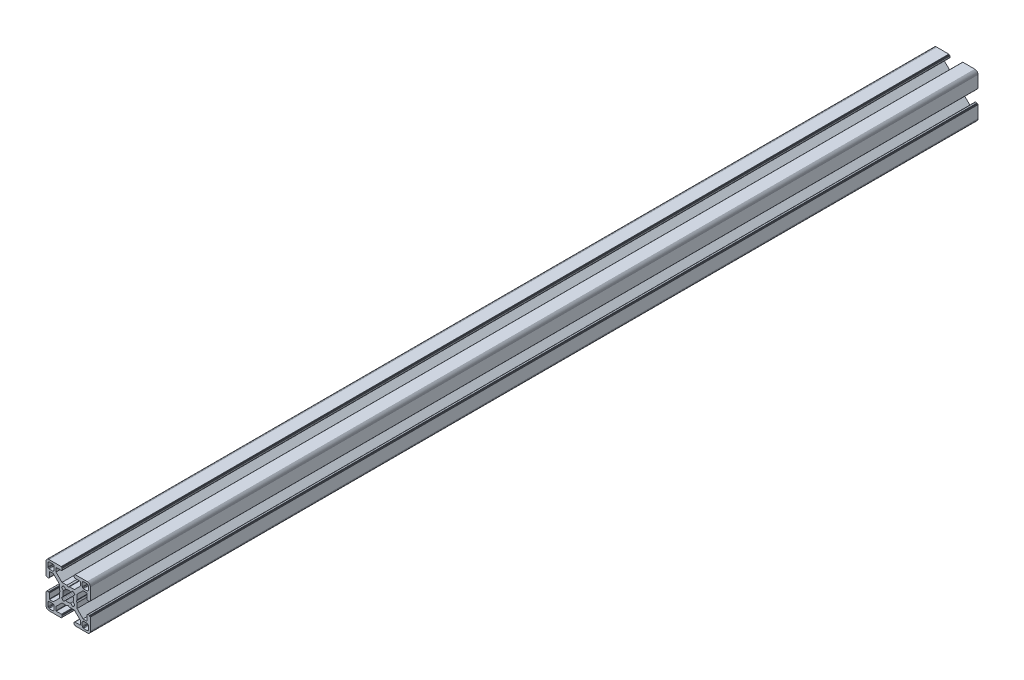
from build123d import *

# Parameters (mm, degrees)
BOSS_EXTRUDE1_DEPTH = 600


with BuildPart() as part:
    # Sketch1 → Boss-Extrude1 (new body)
    with BuildSketch(Plane.XY):
        Polygon((28.34729664, 29.969613999), (28.000000864, 29.999999329), (19.750000909, 29.999999329), (19.715268165, 29.996961355), (19.681595266, 29.987938702), (19.649999216, 29.973205179), (19.621443003, 29.953207821), (19.596790895, 29.928557575), (19.576793537, 29.899999499), (19.562061876, 29.868405312), (19.55303736, 29.834728688), (19.549999386, 29.799999669), (19.549999386, 29.699999839), (19.546961412, 29.665268958), (19.537936896, 29.631596059), (19.523203373, 29.599998146), (19.503207877, 29.571441934), (19.478557631, 29.546789825), (19.449999556, 29.526794329), (19.418403506, 29.512060806), (19.384728745, 29.503038153), (19.349999726, 29.500000179), (19.249999896, 29.500000179), (19.215267517, 29.496958527), (19.181592755, 29.487935874), (19.149996706, 29.47320235), (19.12143863, 29.453206855), (19.096788384, 29.428554746), (19.076791026, 29.399996671), (19.062057503, 29.368402484), (19.05303485, 29.334725859), (19.049996876, 29.299998703), (19.049996876, 28.39999837), (19.059110798, 28.29580945), (19.08618062, 28.194785165), (19.13038119, 28.099997016), (19.190369539, 28.014324653), (19.264324002, 27.94037019), (19.349996366, 27.88038184), (19.444784515, 27.836181271), (19.545806937, 27.809111449), (19.650010894, 27.799984574), (23.050010706, 27.799984574), (23.084741588, 27.7969466), (23.118414487, 27.787923946), (23.150012399, 27.773190423), (23.178568612, 27.753193065), (23.203220721, 27.728542819), (23.223218079, 27.699984744), (23.237949739, 27.668386831), (23.246974255, 27.634713932), (23.25001142, 27.59998608), (23.25001142, 25.049987618), (19.204474482, 20.999982084), (15.900007876, 20.999982084), (15.000008474, 20.48483404), (14.10000814, 20.999982084), (10.795543398, 20.999982084), (7.997342887, 23.801274731), (6.750011387, 25.049984589), (6.750011387, 27.599983051), (6.753049362, 27.634713932), (6.762072946, 27.668386831), (6.776805538, 27.699984744), (6.796801965, 27.728542819), (6.821454073, 27.753193065), (6.850011218, 27.773190423), (6.881607267, 27.787923946), (6.915282029, 27.7969466), (6.950011048, 27.799984574), (10.350011791, 27.799984574), (10.45420071, 27.809098497), (10.555223133, 27.836168318), (10.650011282, 27.880368888), (10.735683645, 27.940357238), (10.809638108, 28.014311701), (10.869626458, 28.099984064), (10.913827027, 28.194772213), (10.940895918, 28.295796498), (10.950010772, 28.399985417), (10.950010772, 29.299985751), (10.946974575, 29.334739239), (10.93795065, 29.368415522), (10.923215933, 29.400009153), (10.903218427, 29.428566473), (10.878566319, 29.45321765), (10.849999264, 29.473204166), (10.818403214, 29.487937689), (10.784728453, 29.496960342), (10.749999434, 29.500000179), (10.649999604, 29.500000179), (10.615270585, 29.503038153), (10.581595823, 29.512060806), (10.549999774, 29.526794329), (10.521441698, 29.546789825), (10.496791452, 29.571441934), (10.476795025, 29.599998146), (10.462061502, 29.631596059), (10.453037918, 29.665268958), (10.449999943, 29.699999839), (10.449999943, 29.799999669), (10.446961969, 29.834728688), (10.437938385, 29.868405312), (10.423205793, 29.899999499), (10.403208435, 29.928557575), (10.378557257, 29.953207821), (10.350000113, 29.973205179), (10.318404064, 29.987938702), (10.284729302, 29.996961355), (10.250000283, 29.999999329), (1.999999397, 29.999999329), (1.652702689, 29.969613999), (1.315958682, 29.879383743), (0.999999233, 29.732050374), (0.714424066, 29.532089829), (0.467910431, 29.285576195), (0.267948955, 28.999999166), (0.120614655, 28.684040532), (0.030384399, 28.34729664), (0, 28.000000864), (0, 19.750000909), (0.003037974, 19.715268165), (0.012061559, 19.681595266), (0.026795082, 19.649999216), (0.046790577, 19.621441141), (0.071442686, 19.596789032), (0.09999983, 19.576793537), (0.13159588, 19.562060013), (0.165270641, 19.55303736), (0.19999966, 19.549999386), (0.299999461, 19.549999386), (0.334728509, 19.546959549), (0.368403242, 19.537936896), (0.399999321, 19.523203373), (0.428556465, 19.503207877), (0.453208573, 19.478555769), (0.473204069, 19.449997693), (0.487937592, 19.418403506), (0.496961176, 19.384728745), (0.499999151, 19.349999726), (0.499999151, 19.249998033), (0.503038056, 19.215269014), (0.512060709, 19.181594253), (0.526794232, 19.150000066), (0.546790194, 19.121441524), (0.571441837, 19.096789882), (0.60000029, 19.076794925), (0.631595686, 19.062061999), (0.665270619, 19.053039982), (0.700000626, 19.050000801), (1.60000096, 19.050000801), (1.704189879, 19.059116587), (1.805213233, 19.086186409), (1.90000045, 19.130385115), (1.985673745, 19.190375328), (2.059627277, 19.264327928), (2.119616325, 19.350002154), (2.163816196, 19.444788441), (2.190886018, 19.545812726), (2.200000872, 19.650001645), (2.200000872, 23.050001457), (2.203039777, 23.084732338), (2.212062431, 23.118405237), (2.226795954, 23.15000315), (2.246792381, 23.178559362), (2.271443558, 23.203211471), (2.300000702, 23.223206967), (2.331596752, 23.23794049), (2.365271513, 23.246965006), (2.400001464, 23.250001117), (4.950000857, 23.250001117), (7.997332093, 20.202670812), (8.995535423, 19.204467788), (8.995535423, 15.900001182), (9.515148227, 15.00000178), (8.995535423, 14.100002378), (8.995535423, 10.795536704), (4.950000857, 6.750002138), (2.400001464, 6.750002138), (2.365271513, 6.753040112), (2.331596752, 6.762063697), (2.300000702, 6.77679722), (2.271443558, 6.796793647), (2.246792381, 6.821444824), (2.226795954, 6.850001968), (2.212062431, 6.881598018), (2.203039777, 6.915272779), (2.200000872, 6.950002729), (2.200000872, 10.350002542), (2.190896812, 10.454174265), (2.16382699, 10.555197618), (2.119627119, 10.649984836), (2.059638071, 10.735658131), (1.985684539, 10.809611663), (1.900011244, 10.869600944), (1.805224027, 10.913800582), (1.704200673, 10.940870404), (1.600011754, 10.949986189), (0.70001142, 10.949986189), (0.665281355, 10.946948596), (0.631606253, 10.937926283), (0.600010578, 10.923193954), (0.571451747, 10.903199537), (0.546799638, 10.87854836), (0.526794232, 10.850000195), (0.512060709, 10.818404146), (0.503038056, 10.784730315), (0.499999151, 10.750000365), (0.499999151, 10.650000535), (0.496961176, 10.615270585), (0.487937592, 10.581596754), (0.473204069, 10.550000705), (0.453208573, 10.521443561), (0.428556465, 10.496791452), (0.399999321, 10.476795956), (0.368403242, 10.462062433), (0.334728509, 10.453038849), (0.299999461, 10.449999943), (0.19999966, 10.449999943), (0.165270641, 10.446961969), (0.13159588, 10.437939316), (0.09999983, 10.423205793), (0.071442686, 10.403209366), (0.046790577, 10.378558189), (0.026795082, 10.350000113), (0.012061559, 10.318404064), (0.003037974, 10.284729302), (0, 10.250000283), (0, 1.999999397), (0.030384399, 1.652702689), (0.120614655, 1.315958682), (0.267948955, 0.999999233), (0.467910431, 0.714424066), (0.714424066, 0.467910431), (0.999999233, 0.267948955), (1.315958682, 0.120614655), (1.652702689, 0.030384399), (1.999999397, 0), (10.250000283, 0), (10.284729302, 0.003037974), (10.318404064, 0.012061559), (10.350000113, 0.026795082), (10.378557257, 0.046790577), (10.403208435, 0.071442686), (10.423205793, 0.09999983), (10.437938385, 0.13159588), (10.446961969, 0.165270641), (10.449999943, 0.19999966), (10.449999943, 0.300000422), (10.453037918, 0.334729441), (10.462061502, 0.368404202), (10.476795025, 0.400000252), (10.496791452, 0.428557396), (10.521441698, 0.453208573), (10.549999774, 0.473205), (10.581595823, 0.487938523), (10.615270585, 0.496961176), (10.649999604, 0.500000082), (10.749999434, 0.500000082), (10.784728453, 0.503038056), (10.818403214, 0.512060709), (10.849999264, 0.526794232), (10.878547894, 0.546800104), (10.903198606, 0.571451747), (10.923194493, 0.6000102), (10.93792742, 0.631606528), (10.946949437, 0.66528146), (10.950010772, 0.699984975), (10.950010772, 1.599985308), (10.940895918, 1.704174228), (10.913827027, 1.805197581), (10.869626458, 1.89998573), (10.809638108, 1.985658094), (10.735683645, 2.059612557), (10.650011282, 2.119600674), (10.555223133, 2.163801476), (10.45420071, 2.190870367), (10.350011791, 2.199985221), (6.950011048, 2.199985221), (6.915282029, 2.203024126), (6.881607267, 2.212046779), (6.850011218, 2.226780302), (6.821454073, 2.246776729), (6.796801965, 2.271427907), (6.776805538, 2.299985982), (6.762072946, 2.331582032), (6.753049362, 2.365256793), (6.750011387, 2.399985812), (6.750011387, 4.949985206), (9.787457566, 7.990785077), (10.795545277, 8.999985833), (14.100010019, 8.999985833), (15.000010353, 9.515133877), (15.900009756, 8.999985833), (19.204476361, 8.999985833), (20.21256413, 7.990786065), (23.25001142, 4.949988235), (23.25001142, 2.399988841), (23.246974255, 2.365256793), (23.237949739, 2.331582032), (23.223218079, 2.299985982), (23.203220721, 2.271427907), (23.178568612, 2.246776729), (23.150012399, 2.226780302), (23.118414487, 2.212046779), (23.084741588, 2.203024126), (23.050010706, 2.199985221), (19.650010894, 2.199985221), (19.545806937, 2.190883319), (19.444784515, 2.163814428), (19.349996366, 2.119613626), (19.264324002, 2.059625509), (19.190369539, 1.985671046), (19.13038119, 1.899998682), (19.08618062, 1.805210533), (19.059110798, 1.70418718), (19.049996876, 1.599998261), (19.049996876, 0.699997927), (19.053035506, 0.665268966), (19.062058795, 0.631594374), (19.076792915, 0.599998603), (19.096790813, 0.571440905), (19.121441524, 0.546790194), (19.149999978, 0.526794306), (19.181596306, 0.51206138), (19.215271238, 0.503039363), (19.249999896, 0.500000082), (19.349999726, 0.500000082), (19.384728745, 0.496961176), (19.418403506, 0.487938523), (19.449999556, 0.473205), (19.478557631, 0.453208573), (19.503207877, 0.428557396), (19.523203373, 0.400000252), (19.537936896, 0.368404202), (19.546961412, 0.334729441), (19.549999386, 0.300000422), (19.549999386, 0.19999966), (19.55303736, 0.165270641), (19.562061876, 0.13159588), (19.576793537, 0.09999983), (19.596789964, 0.071441755), (19.621442072, 0.046789646), (19.649998285, 0.02679415), (19.681594335, 0.012060627), (19.715267234, 0.003037043), (19.750000909, 0), (28.000000864, 0), (28.34729664, 0.030384399), (28.684040532, 0.120614655), (28.999999166, 0.267948955), (29.285576195, 0.467910431), (29.532089829, 0.714424066), (29.732050374, 0.999999233), (29.879383743, 1.315958682), (29.969613999, 1.652702689), (29.999999329, 1.999999397), (29.999999329, 10.250000283), (29.996974806, 10.284715361), (29.987951516, 10.318389952), (29.973217396, 10.349985723), (29.953219499, 10.378543421), (29.928568787, 10.403194133), (29.899999499, 10.423205793), (29.868405312, 10.437939316), (29.834728688, 10.446961969), (29.799999669, 10.449999943), (29.699999839, 10.449999943), (29.664909937, 10.453400043), (29.631233313, 10.462423628), (29.599637263, 10.477157151), (29.57108105, 10.497152646), (29.546427079, 10.521804755), (29.526433446, 10.550361899), (29.511699923, 10.581957949), (29.502675407, 10.615631779), (29.499637433, 10.650361729), (29.499637433, 10.750361559), (29.49697202, 10.784715548), (29.487949367, 10.818389378), (29.473215844, 10.849985428), (29.453220348, 10.878542572), (29.428568239, 10.90319468), (29.400010164, 10.923190176), (29.368415977, 10.937923699), (29.334741215, 10.946947284), (29.300012197, 10.949986189), (28.400011863, 10.949986189), (28.29581215, 10.9408876), (28.194787865, 10.913817778), (28.099999716, 10.86961814), (28.014327352, 10.809628859), (27.940374752, 10.735675327), (27.880384539, 10.650002032), (27.836185833, 10.555214814), (27.809114148, 10.454191461), (27.800000225, 10.350002542), (27.800000225, 6.950002729), (27.796962251, 6.915272779), (27.787939598, 6.881598018), (27.773206075, 6.850001968), (27.753208716, 6.821444824), (27.728558471, 6.796793647), (27.700000395, 6.77679722), (27.668404345, 6.762063697), (27.634729584, 6.753040112), (27.599998702, 6.750002138), (25.05000024, 6.750002138), (23.809199132, 7.99080223), (21.004464477, 10.795534588), (21.004464477, 14.100000262), (20.484851673, 14.999999665), (21.004464477, 15.899999067), (21.004464477, 19.204465672), (25.05000024, 23.250001117), (27.599998702, 23.250001117), (27.634729584, 23.246965006), (27.668404345, 23.23794049), (27.700000395, 23.223206967), (27.728558471, 23.203211471), (27.753208716, 23.178559362), (27.773206075, 23.15000315), (27.787939598, 23.118405237), (27.796962251, 23.084732338), (27.800000225, 23.050001457), (27.800000225, 19.650001645), (27.809114148, 19.545812726), (27.836185833, 19.444788441), (27.880384539, 19.350002154), (27.940370508, 19.264323684), (28.014323108, 19.190371084), (28.099995472, 19.130380872), (28.194783621, 19.086182165), (28.295807906, 19.059112343), (28.400001069, 19.050000801), (29.300001402, 19.050000801), (29.334730421, 19.053040638), (29.368405183, 19.062063291), (29.39999937, 19.076796814), (29.42819671, 19.097149726), (29.452848353, 19.1218023), (29.472843309, 19.150360754), (29.487576235, 19.181955219), (29.496598252, 19.215630151), (29.499637433, 19.250359227), (29.499637433, 19.35036092), (29.502675407, 19.385089939), (29.511699923, 19.4187647), (29.526433446, 19.450358887), (29.546427079, 19.478916963), (29.57108105, 19.503569071), (29.599637263, 19.523564567), (29.631233313, 19.53829809), (29.664909937, 19.547320743), (29.699999839, 19.549999386), (29.799999669, 19.549999386), (29.834728688, 19.55303736), (29.868405312, 19.562060013), (29.899999499, 19.576793537), (29.928557575, 19.596789032), (29.953207821, 19.621441141), (29.973205179, 19.649999216), (29.987938702, 19.681595266), (29.996961355, 19.715268165), (29.999999329, 19.750000909), (29.999999329, 28.000000864), (29.969613999, 28.34729664), (29.879383743, 28.684040532), (29.732050374, 28.999999166), (29.532089829, 29.285576195), (29.285576195, 29.532089829), (28.999999166, 29.732050374), (28.684040532, 29.879383743), align=None)
        Polygon((1.299998723, 25.499999523), (1.299998723, 27.699999511), (1.312309876, 27.856435627), (1.348942518, 28.009016067), (1.408992335, 28.153989464), (1.490981318, 28.287785128), (1.592892222, 28.407108039), (1.71221327, 28.50901708), (1.846008119, 28.591006994), (1.9909814, 28.651056811), (2.143563703, 28.687689453), (2.299998887, 28.699999675), (4.499998875, 28.699999675), (4.656434059, 28.687689453), (4.809016362, 28.651056811), (4.953989759, 28.591006994), (5.087784491, 28.50901708), (5.207106471, 28.407108039), (5.309016444, 28.287785128), (5.391005427, 28.153989464), (5.451056175, 28.009016067), (5.487687886, 27.856435627), (5.499999039, 27.699999511), (5.499999039, 25.499999523), (5.487687886, 25.34356527), (5.451056175, 25.190982968), (5.391005427, 25.04600957), (5.309016444, 24.912213907), (5.207106471, 24.792892858), (5.087784491, 24.690981954), (4.953989759, 24.60899204), (4.809016362, 24.548944086), (4.656434059, 24.512309581), (4.499998875, 24.499999359), (2.299998887, 24.499999359), (2.143563703, 24.512309581), (1.9909814, 24.548944086), (1.846008119, 24.60899204), (1.71221327, 24.690981954), (1.592892222, 24.792892858), (1.490981318, 24.912213907), (1.408992335, 25.04600957), (1.348942518, 25.190982968), (1.312309876, 25.34356527), align=None, mode=Mode.SUBTRACT)
        Polygon((25.34356527, 28.687689453), (25.499999523, 28.699999675), (27.699999511, 28.699999675), (27.856435627, 28.687689453), (28.009017929, 28.651056811), (28.153991327, 28.591006994), (28.28778699, 28.50901708), (28.407108039, 28.407108039), (28.50901708, 28.287785128), (28.591006994, 28.153989464), (28.651056811, 28.009016067), (28.687689453, 27.856435627), (28.700001538, 27.699999511), (28.700001538, 25.499999523), (28.687689453, 25.34356527), (28.651056811, 25.190982968), (28.591006994, 25.04600957), (28.50901708, 24.912213907), (28.407108039, 24.792892858), (28.28778699, 24.690981954), (28.153991327, 24.60899204), (28.009017929, 24.548944086), (27.856435627, 24.512309581), (27.699999511, 24.499999359), (25.499999523, 24.499999359), (25.34356527, 24.512309581), (25.190982968, 24.548944086), (25.04600957, 24.60899204), (24.912215769, 24.690981954), (24.792892858, 24.792892858), (24.690981954, 24.912213907), (24.608993903, 25.04600957), (24.548944086, 25.190982968), (24.512311444, 25.34356527), (24.500001222, 25.499999523), (24.500001222, 27.699999511), (24.512311444, 27.856435627), (24.548944086, 28.009016067), (24.608993903, 28.153989464), (24.690981954, 28.287785128), (24.792892858, 28.407108039), (24.912215769, 28.50901708), (25.04600957, 28.591006994), (25.190982968, 28.651056811), align=None, mode=Mode.SUBTRACT)
        Polygon((14.999999665, 18.649999052), (15.550030395, 18.608318642), (16.087498516, 18.484227359), (16.600128263, 18.280562013), (18.13592948, 19.518401474), (18.644984812, 19.11874488), (19.103571773, 18.662061542), (19.505336881, 18.154669553), (18.280562013, 16.600130126), (18.484227359, 16.087498516), (18.608318642, 15.550030395), (18.649999052, 14.999999665), (18.608318642, 14.449968934), (18.484227359, 13.912500814), (18.280562013, 13.399870135), (19.505336881, 11.845329776), (19.103571773, 11.337937787), (18.644984812, 10.881252587), (18.13592948, 10.481598787), (16.600128263, 11.719437316), (16.087498516, 11.515771039), (15.550030395, 11.391680688), (14.999999665, 11.349999346), (14.449968934, 11.391680688), (13.912500814, 11.515771039), (13.399870135, 11.719437316), (11.864069849, 10.481598787), (11.355013587, 10.881252587), (10.896427557, 11.337937787), (10.494662449, 11.845329776), (11.719438247, 13.399870135), (11.515771039, 13.912500814), (11.391680688, 14.449968934), (11.349999346, 14.999999665), (11.391680688, 15.550030395), (11.515771039, 16.087498516), (11.719438247, 16.600130126), (10.494662449, 18.154669553), (10.896427557, 18.662061542), (11.355013587, 19.11874488), (11.864069849, 19.518401474), (13.399870135, 18.280562013), (13.912500814, 18.484227359), (14.449968934, 18.608318642), align=None, mode=Mode.SUBTRACT)
        Polygon((4.499998875, 1.299999771), (2.299998887, 1.299999771), (2.143563703, 1.312310807), (1.9909814, 1.348942518), (1.846008119, 1.408992335), (1.71221327, 1.490982249), (1.592892222, 1.592892222), (1.490981318, 1.712214202), (1.408992335, 1.846008934), (1.348942518, 1.990982331), (1.312309876, 2.143564634), (1.299998723, 2.299998887), (1.299998723, 4.499999806), (1.312309876, 4.656434059), (1.348942518, 4.809017293), (1.408992335, 4.95399069), (1.490981318, 5.087785423), (1.592892222, 5.207106471), (1.71221327, 5.309017375), (1.846008119, 5.391006358), (1.9909814, 5.451056175), (2.143563703, 5.487688817), (2.299998887, 5.49999997), (4.499998875, 5.49999997), (4.656434059, 5.487688817), (4.809016362, 5.451056175), (4.953989759, 5.391006358), (5.087784491, 5.309017375), (5.207106471, 5.207106471), (5.309016444, 5.087785423), (5.391005427, 4.95399069), (5.451056175, 4.809017293), (5.487687886, 4.656434059), (5.499999039, 4.499999806), (5.499999039, 2.299998887), (5.487687886, 2.143564634), (5.451056175, 1.990982331), (5.391005427, 1.846008934), (5.309016444, 1.712214202), (5.207106471, 1.592892222), (5.087784491, 1.490982249), (4.953989759, 1.408992335), (4.809016362, 1.348942518), (4.656434059, 1.312310807), align=None, mode=Mode.SUBTRACT)
        Polygon((27.699999511, 1.299999771), (25.499999523, 1.299999771), (25.34356527, 1.312310807), (25.190982968, 1.348942518), (25.04600957, 1.408992335), (24.912215769, 1.490982249), (24.792892858, 1.592892222), (24.690981954, 1.712214202), (24.608993903, 1.846008934), (24.548944086, 1.990982331), (24.512311444, 2.143564634), (24.500001222, 2.299998887), (24.500001222, 4.499999806), (24.512311444, 4.656434059), (24.548944086, 4.809017293), (24.608993903, 4.95399069), (24.690981954, 5.087785423), (24.792892858, 5.207106471), (24.912215769, 5.309017375), (25.04600957, 5.391006358), (25.190982968, 5.451056175), (25.34356527, 5.487688817), (25.499999523, 5.49999997), (27.699999511, 5.49999997), (27.856435627, 5.487688817), (28.009017929, 5.451056175), (28.153991327, 5.391006358), (28.28778699, 5.309017375), (28.407108039, 5.207106471), (28.50901708, 5.087785423), (28.591006994, 4.95399069), (28.651056811, 4.809017293), (28.687689453, 4.656434059), (28.700001538, 4.499999806), (28.700001538, 2.299998887), (28.687689453, 2.143564634), (28.651056811, 1.990982331), (28.591006994, 1.846008934), (28.50901708, 1.712214202), (28.407108039, 1.592892222), (28.28778699, 1.490982249), (28.153991327, 1.408992335), (28.009017929, 1.348942518), (27.856435627, 1.312310807), align=None, mode=Mode.SUBTRACT)
    extrude(amount=-BOSS_EXTRUDE1_DEPTH)


solid = part.part
